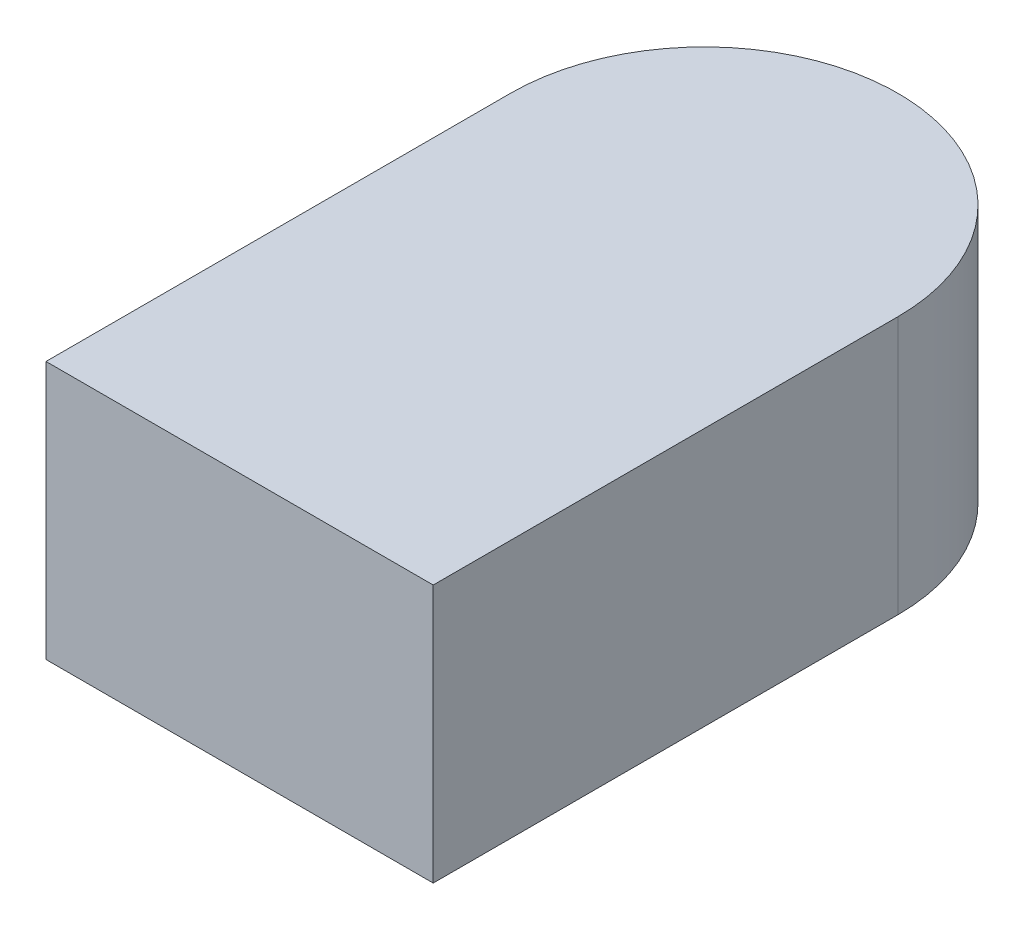
from build123d import *

# Parameters (mm, degrees)
BOSS_EXTRUDE1_DEPTH = 0.2


with BuildPart() as part:
    # Sketch1 → Boss-Extrude1 (new body)
    with BuildSketch(Plane(origin=(0, 0, 0), x_dir=(1, 0, 0), z_dir=(0, 1, 0))):
        with BuildLine():
            Line((-0.15, 0.18), (-0.15, -0.18))
            Line((-0.15, -0.18), (0.15, -0.18))
            Line((0.15, -0.18), (0.15, 0.18))
            ThreePointArc((0.15, 0.18), (0, 0.33), (-0.15, 0.18))
        make_face()
    extrude(amount=BOSS_EXTRUDE1_DEPTH)


solid = part.part
